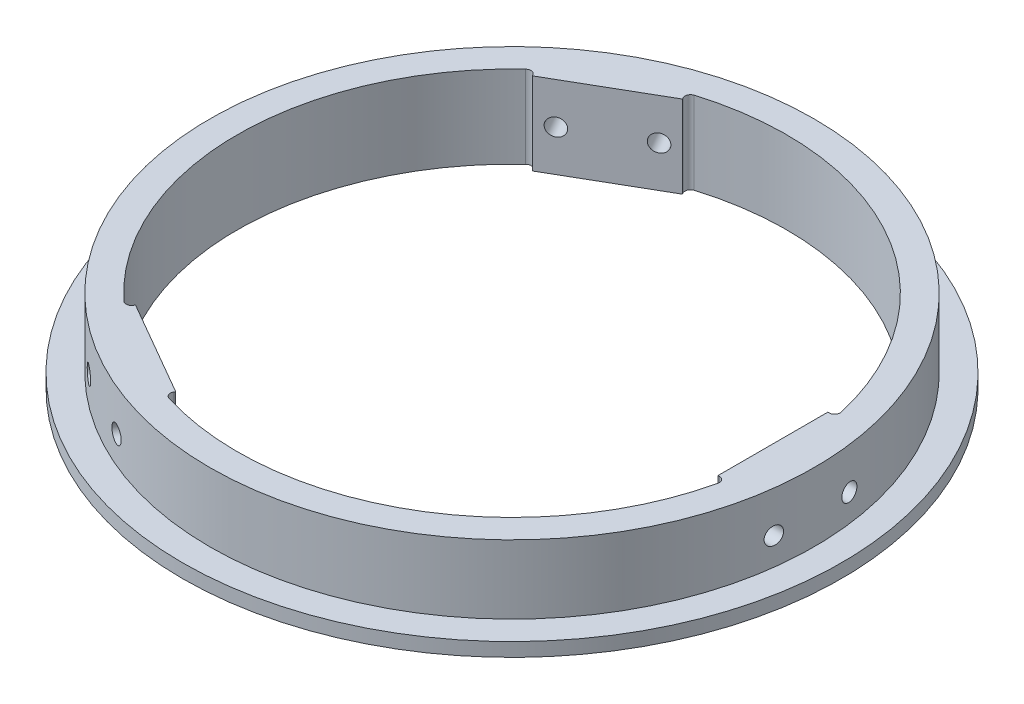
from build123d import *

# Parameters (mm, degrees)
SKETCH1_R                = 152.4
SKETCH1_R_2              = 127
BOSS_EXTRUDE1_DEPTH      = 38.1
SKETCH2_R                = 152.4
SKETCH2_R_2              = 139.7
CUT_EXTRUDE1_DEPTH       = 31.75
BOSS_EXTRUDE2_DEPTH      = 38.1
FILLET1_R                = 2.54
HOLE1_D                  = 8
HOLE1_DEPTH              = 87.532271537
CIRPATTERN1_COUNT        = 3
FILLET1_OF_CIRPATTERN1_R = 2.54


with BuildPart() as part:
    # Sketch1 → Boss-Extrude1 (new body)
    with BuildSketch(Plane(origin=(0, 0, 0), x_dir=(1, 0, 0), z_dir=(0, 1, 0))):
        Circle(SKETCH1_R)
        Circle(SKETCH1_R_2, mode=Mode.SUBTRACT)
    extrude(amount=BOSS_EXTRUDE1_DEPTH)

    # Sketch2 → Cut-Extrude1 (cut)
    with BuildSketch(Plane(origin=(0, 38.1, 0), x_dir=(1, 0, 0), z_dir=(0, 1, 0))):
        Circle(SKETCH2_R)
        Circle(SKETCH2_R_2, mode=Mode.SUBTRACT)
    extrude(amount=-CUT_EXTRUDE1_DEPTH, mode=Mode.SUBTRACT)

    # Sketch3 → Boss-Extrude2 (add, through all)
    with BuildSketch(Plane(origin=(0, 38.1, 0), x_dir=(1, 0, 0), z_dir=(0, 1, 0))):
        with BuildLine():
            Line((120.65, 25.4), (120.65, -25.4))
            Line((120.65, -25.4), (124.434078933, -25.4))
            ThreePointArc((124.434078933, -25.4), (127, 0), (124.434078933, 25.4))
            Line((124.434078933, 25.4), (120.65, 25.4))
        make_face()
    boss_extrude2 = extrude(amount=-BOSS_EXTRUDE2_DEPTH)

    # Fillet1
    fillet1_edges = [part.edges().sort_by_distance(p)[0] for p in [
        (124.434078933, 19.05, -25.4),
        (124.434078933, 19.05, 25.4),
    ]]
    fillet(fillet1_edges, radius=FILLET1_R)

    # Hole1
    with Locations(Plane(origin=(120.65, 0, -417.943859866), x_dir=(0, 0, 1), z_dir=(-1, 0, 0))):
        with Locations((400.481359866, 19.05), (435.406359866, 19.05)):
            hole1 = Hole(HOLE1_D / 2, depth=HOLE1_DEPTH)

    # CirPattern1: Boss-Extrude2, Hole1 ×3 about axis
    cirpattern1_axis = Axis((0, 0, 0), (0, 1, 0))
    for i in range(1, CIRPATTERN1_COUNT):
        add(boss_extrude2.rotate(cirpattern1_axis, i * 360 / CIRPATTERN1_COUNT))
        add(hole1.rotate(cirpattern1_axis, i * 360 / CIRPATTERN1_COUNT), mode=Mode.SUBTRACT)

    # Fillet1 of CirPattern1
    fillet1_of_cirpattern1_edges = [part.edges().sort_by_distance(p)[0] for p in [
        (-84.214084723, 19.05, -95.063073453),
        (-40.219994211, 19.05, -120.463073453),
        (-40.219994211, 19.05, 120.463073453),
        (-84.214084723, 19.05, 95.063073453),
    ]]
    fillet(fillet1_of_cirpattern1_edges, radius=FILLET1_OF_CIRPATTERN1_R)


solid = part.part
